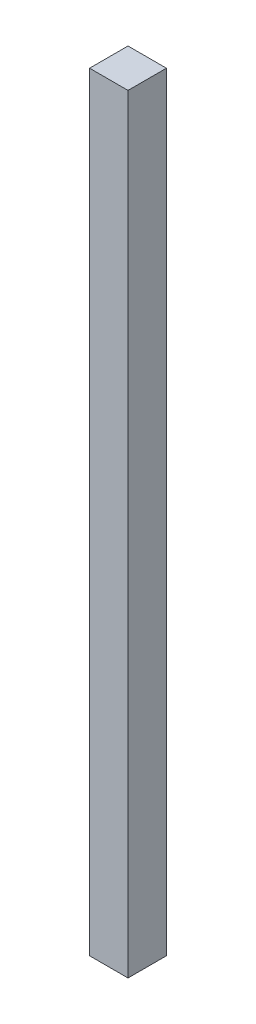
from build123d import *

# Parameters (mm, degrees)
SKETCH1_W           = 40
SKETCH1_H           = 40
BOSS_EXTRUDE1_DEPTH = 800


with BuildPart() as part:
    # Sketch1 → Boss-Extrude1 (new body)
    with BuildSketch(Plane(origin=(0, 0, 0), x_dir=(1, 0, 0), z_dir=(0, 1, 0))):
        Rectangle(SKETCH1_W, SKETCH1_H)
    extrude(amount=BOSS_EXTRUDE1_DEPTH)


solid = part.part
